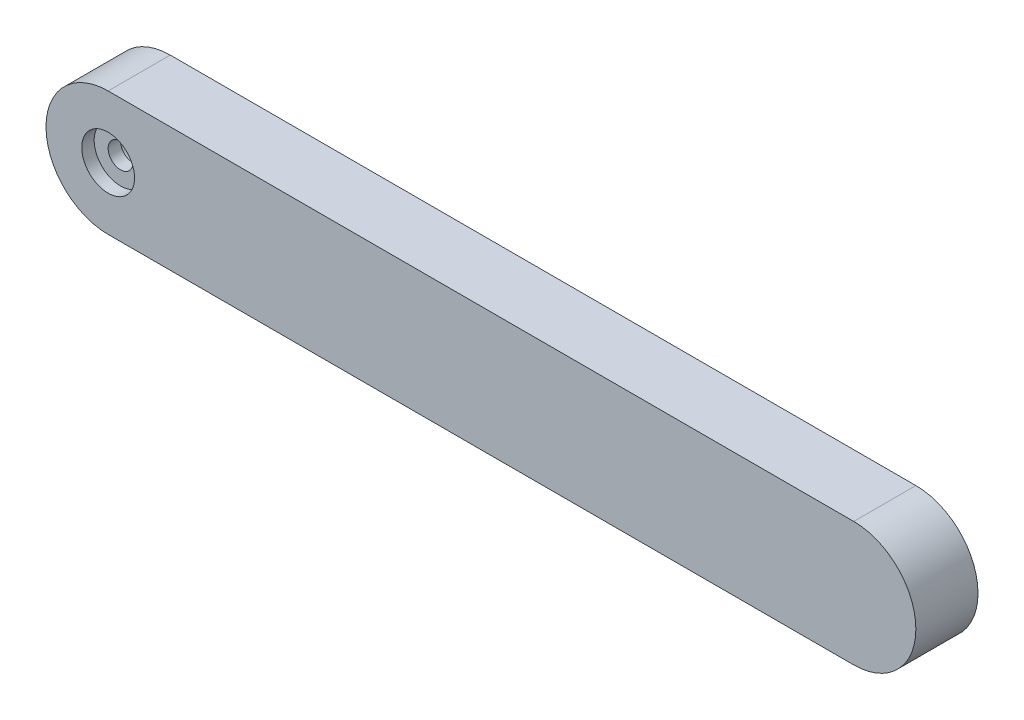
from build123d import *

# Parameters (mm, degrees)
BOSS_EXTRUDE1_DEPTH = 5
SKETCH2_R           = 2.0125
CUT_EXTRUDE1_DEPTH  = 3
SKETCH3_R           = 2.125
CUT_EXTRUDE2_DEPTH  = 1
SKETCH4_R           = 1
CUT_EXTRUDE3_DEPTH  = 66.314623171


with BuildPart() as part:
    # Sketch1 → Boss-Extrude1 (new body)
    with BuildSketch(Plane.XY):
        with BuildLine():
            Line((0, 5), (60, 5))
            ThreePointArc((60, 5), (65, 0), (60, -5))
            Line((60, -5), (0, -5))
            ThreePointArc((0, -5), (-5, 0), (0, 5))
        make_face()
    extrude(amount=BOSS_EXTRUDE1_DEPTH)

    # Sketch2 → Cut-Extrude1 (cut)
    with BuildSketch(Plane(origin=(0, 0, 0), x_dir=(-1, 0, 0), z_dir=(0, 0, -1))):
        Circle(SKETCH2_R)
    extrude(amount=-CUT_EXTRUDE1_DEPTH, mode=Mode.SUBTRACT)

    # Sketch3 → Cut-Extrude2 (cut)
    with BuildSketch(Plane.XY.offset(5)):
        Circle(SKETCH3_R)
    extrude(amount=-CUT_EXTRUDE2_DEPTH, mode=Mode.SUBTRACT)

    # Sketch4 → Cut-Extrude3 (cut, through all)
    with BuildSketch(Plane.XY.offset(4)):
        Circle(SKETCH4_R)
    extrude(amount=-CUT_EXTRUDE3_DEPTH, mode=Mode.SUBTRACT)


solid = part.part
